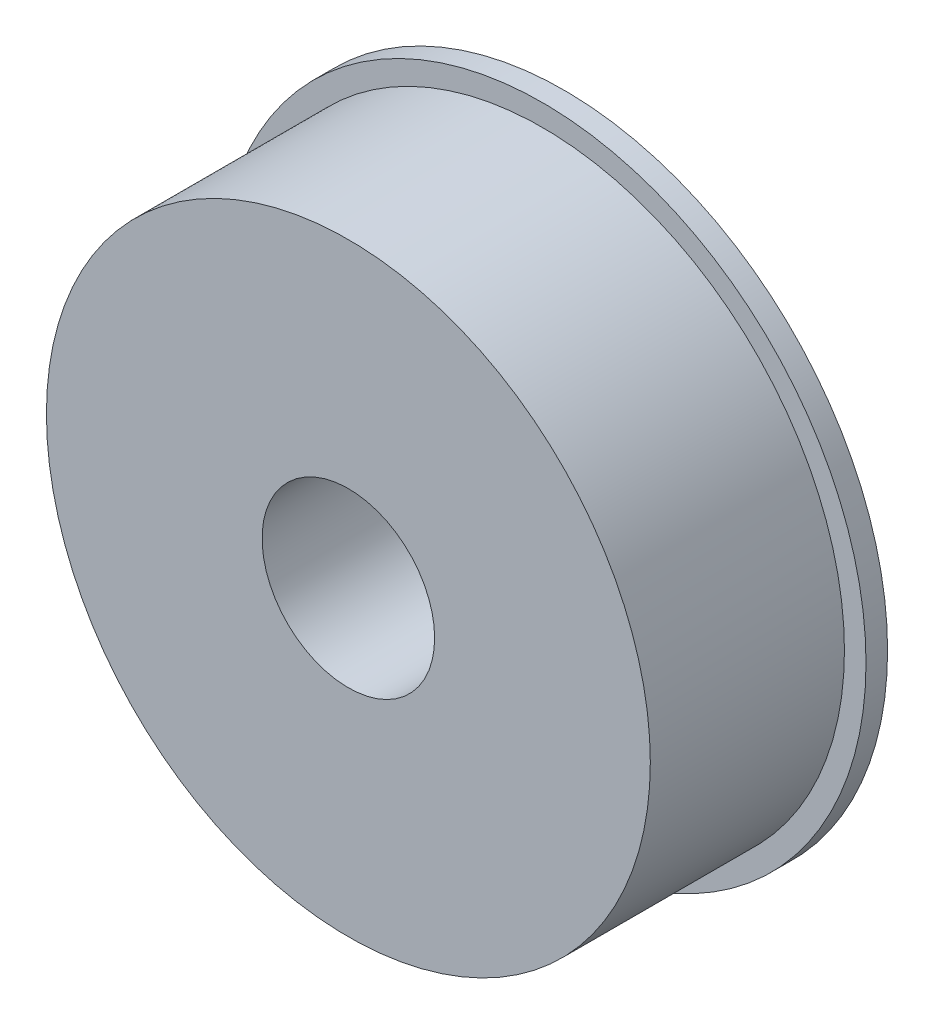
from build123d import *

# Parameters (mm, degrees)
SKETCH1_R           = 87.5
SKETCH1_R_2         = 25
BOSS_EXTRUDE1_DEPTH = 62.5
SKETCH2_R           = 93.75
BOSS_EXTRUDE3_DEPTH = 6.25


with BuildPart() as part:
    # Sketch1 → Boss-Extrude1 (new body)
    with BuildSketch(Plane.XY):
        Circle(SKETCH1_R)
        Circle(SKETCH1_R_2, mode=Mode.SUBTRACT)
    extrude(amount=BOSS_EXTRUDE1_DEPTH)

    # Sketch2 → Boss-Extrude3 (add)
    with BuildSketch(Plane.XY):
        Circle(SKETCH2_R)
    extrude(amount=BOSS_EXTRUDE3_DEPTH)


solid = part.part
